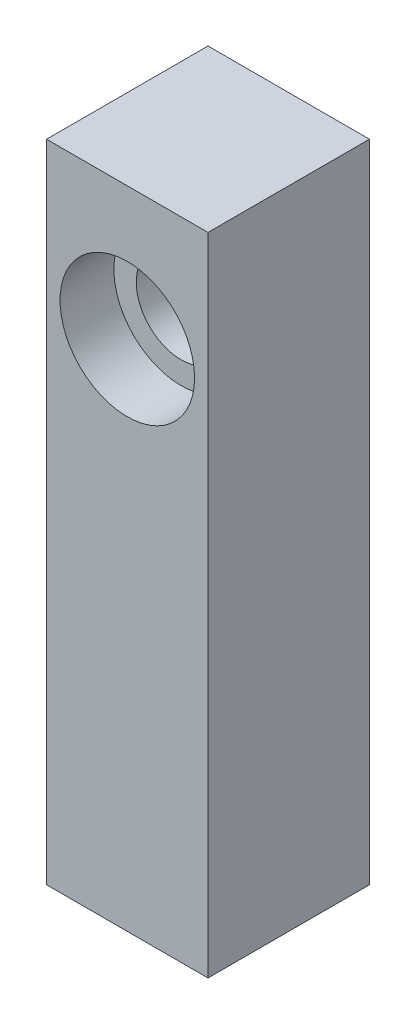
from build123d import *

# Parameters (mm, degrees)
SKETCH1_W                 = 18
SKETCH1_H                 = 18
BOSS_EXTRUDE1_DEPTH       = 72
SKETCH2_R                 = 5
CUT_EXTRUDE1_DEPTH        = 19
M6X1_0_TAPPED_HOLE1_D     = 5
M6X1_0_TAPPED_HOLE1_DEPTH = 29
M6X1_0_TAPPED_HOLE1_TIP   = 1.502151548
SKETCH6_R                 = 7.5
CUT_EXTRUDE2_DEPTH        = 6


with BuildPart() as part:
    # Sketch1 → Boss-Extrude1 (new body)
    with BuildSketch(Plane(origin=(0, 0, 0), x_dir=(1, 0, 0), z_dir=(0, 1, 0))):
        with Locations((-33.958762887, 4.268041237)):
            Rectangle(SKETCH1_W, SKETCH1_H)
    extrude(amount=BOSS_EXTRUDE1_DEPTH)

    # Sketch2 → Cut-Extrude1 (cut, through all)
    with BuildSketch(Plane.XY.offset(4.731958763)):
        with Locations((-33.958762887, 57.2)):
            Circle(SKETCH2_R)
    extrude(amount=-CUT_EXTRUDE1_DEPTH, mode=Mode.SUBTRACT)

    # M6x1.0 Tapped Hole1
    with Locations(Plane(origin=(0, 0, 0), x_dir=(-1, 0, 0), z_dir=(0, -1, 0))):
        with Locations((33.958762887, 4.268041237)):
            Hole(M6X1_0_TAPPED_HOLE1_D / 2, depth=M6X1_0_TAPPED_HOLE1_DEPTH)
            with Locations((0, 0, -(M6X1_0_TAPPED_HOLE1_DEPTH + M6X1_0_TAPPED_HOLE1_TIP / 2))):  # 118° drill point
                Cone(0, M6X1_0_TAPPED_HOLE1_D / 2, M6X1_0_TAPPED_HOLE1_TIP, mode=Mode.SUBTRACT)

    # Sketch6 → Cut-Extrude2 (cut)
    with BuildSketch(Plane.XY.offset(4.731958763)):
        with Locations((-33.958762887, 57.2)):
            Circle(SKETCH6_R)
    extrude(amount=-CUT_EXTRUDE2_DEPTH, mode=Mode.SUBTRACT)


solid = part.part
